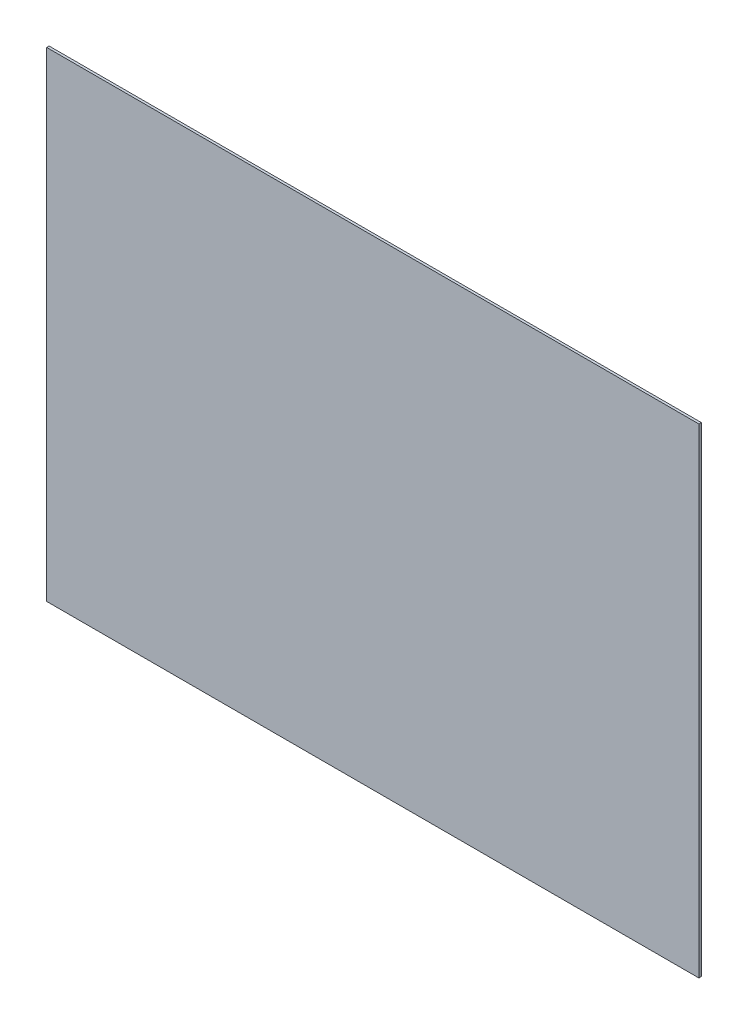
from build123d import *

# Parameters (mm, degrees)
SKETCH1_W      = 13400
SKETCH1_H      = 9858
EXTRUDE1_DEPTH = 50


with BuildPart() as part:
    # Sketch1 → Extrude1 (new body)
    with BuildSketch(Plane.XY):
        with Locations((1200, 1129)):
            Rectangle(SKETCH1_W, SKETCH1_H)
    extrude(amount=-EXTRUDE1_DEPTH)


solid = part.part
